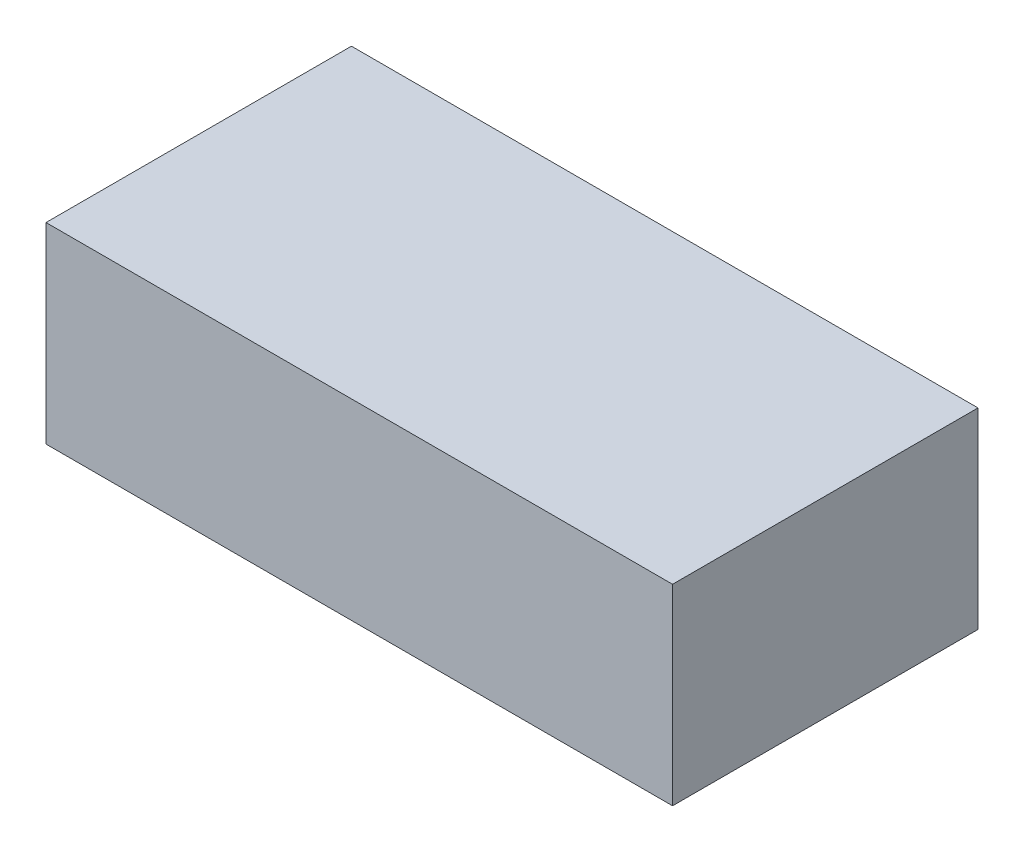
from build123d import *

# Parameters (mm, degrees)
SKETCH1_W           = 80
SKETCH1_H           = 39
BOSS_EXTRUDE1_DEPTH = 24.5


with BuildPart() as part:
    # Sketch1 → Boss-Extrude1 (new body)
    with BuildSketch(Plane(origin=(0, 0, 0), x_dir=(1, 0, 0), z_dir=(0, 1, 0))):
        Rectangle(SKETCH1_W, SKETCH1_H)
    extrude(amount=BOSS_EXTRUDE1_DEPTH)


solid = part.part
